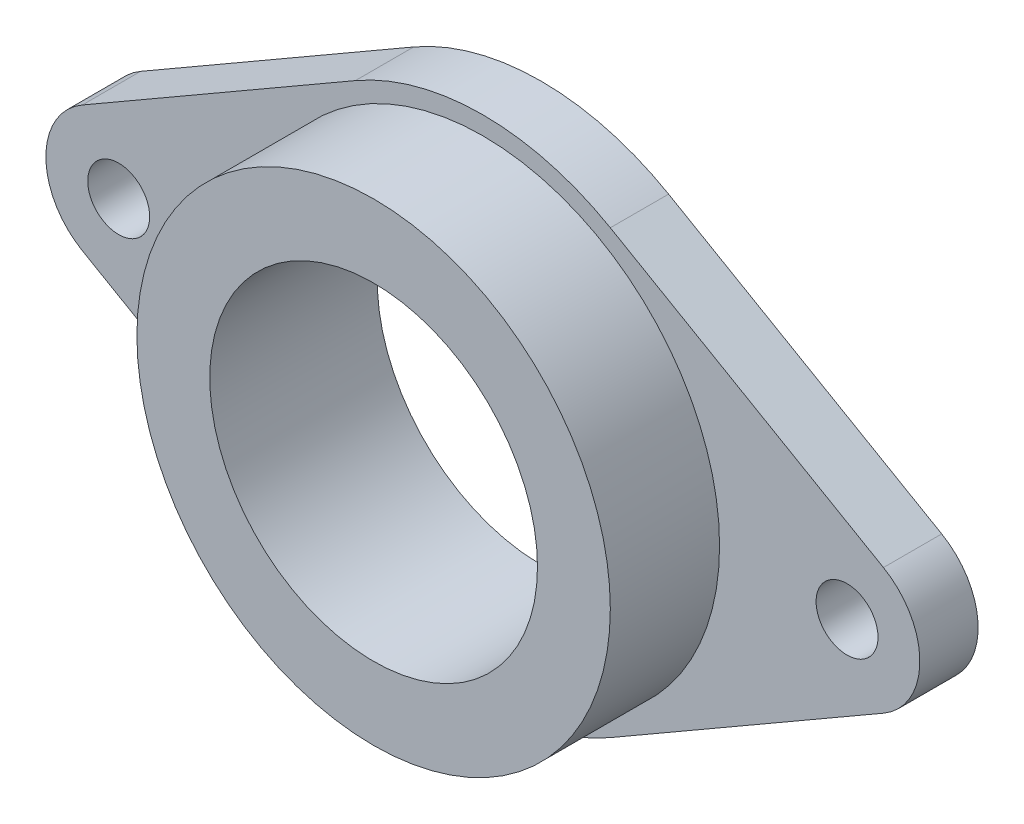
from build123d import *

# Parameters (mm, degrees)
SKETCH2_R           = 4.25
SKETCH2_R_2         = 32.5
BOSS_EXTRUDE1_DEPTH = 8
SKETCH2_4_R         = 32.5
SKETCH2_4_R_2       = 22.5
BOSS_EXTRUDE2_DEPTH = 23


with BuildPart() as part:
    # Sketch2 → Boss-Extrude1 (new body)
    with BuildSketch(Plane.XY):
        with BuildLine():
            ThreePointArc((17.5, 30.310889132), (0, 35), (-17.5, 30.310889132))
            Line((-17.5, 30.310889132), (-55, 8.660254038))
            ThreePointArc((-55, 8.660254038), (-60, 0), (-55, -8.660254038))
            Line((-55, -8.660254038), (-17.5, -30.310889132))
            ThreePointArc((-17.5, -30.310889132), (0, -35), (17.5, -30.310889132))
            Line((17.5, -30.310889132), (55, -8.660254038))
            ThreePointArc((55, -8.660254038), (60, 0), (55, 8.660254038))
            Line((55, 8.660254038), (17.5, 30.310889132))
        make_face()
        with Locations((-50, 0)):
            Circle(SKETCH2_R, mode=Mode.SUBTRACT)
        Circle(SKETCH2_R_2, mode=Mode.SUBTRACT)
        with Locations((50, 0)):
            Circle(SKETCH2_R, mode=Mode.SUBTRACT)
    extrude(amount=BOSS_EXTRUDE1_DEPTH)

    # Sketch2_4 → Boss-Extrude2 (add)
    with BuildSketch(Plane.XY):
        Circle(SKETCH2_4_R)
        Circle(SKETCH2_4_R_2, mode=Mode.SUBTRACT)
    extrude(amount=BOSS_EXTRUDE2_DEPTH)


solid = part.part
